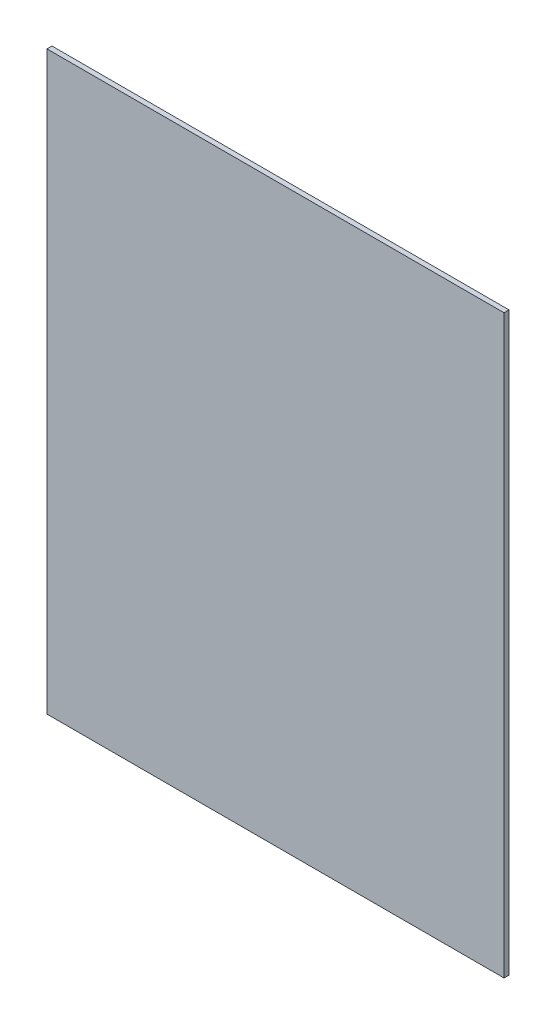
from build123d import *

# Parameters (mm, degrees)
CROQUIS1_W              = 238
CROQUIS1_H              = 2.6
SALIENTE_EXTRUIR1_DEPTH = 300


with BuildPart() as part:
    # Croquis1 → Saliente-Extruir1 (new body)
    with BuildSketch(Plane(origin=(0, 0, 0), x_dir=(1, 0, 0), z_dir=(0, 1, 0))):
        Rectangle(CROQUIS1_W, CROQUIS1_H)
    extrude(amount=SALIENTE_EXTRUIR1_DEPTH)


solid = part.part
